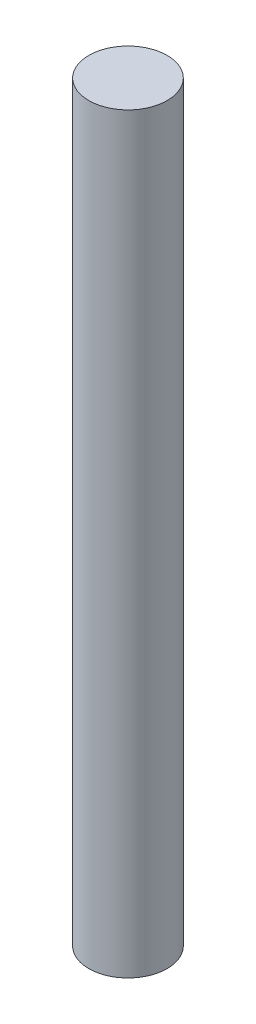
from build123d import *

# Parameters (mm, degrees)
CROQUIS1_R                   = 0.5
SALIENTE_EXTRUIR1_DEPTH      = 8
SALIENTE_EXTRUIR1_DEPTH_BACK = 1.6


with BuildPart() as part:
    # Croquis1 → Saliente-Extruir1 (new body, two sides)
    with BuildSketch(Plane(origin=(0, 0, 0), x_dir=(1, 0, 0), z_dir=(0, 1, 0))) as saliente_extruir1_sk:
        Circle(CROQUIS1_R)
    extrude(amount=SALIENTE_EXTRUIR1_DEPTH)
    extrude(saliente_extruir1_sk.sketch, amount=-SALIENTE_EXTRUIR1_DEPTH_BACK)


solid = part.part
